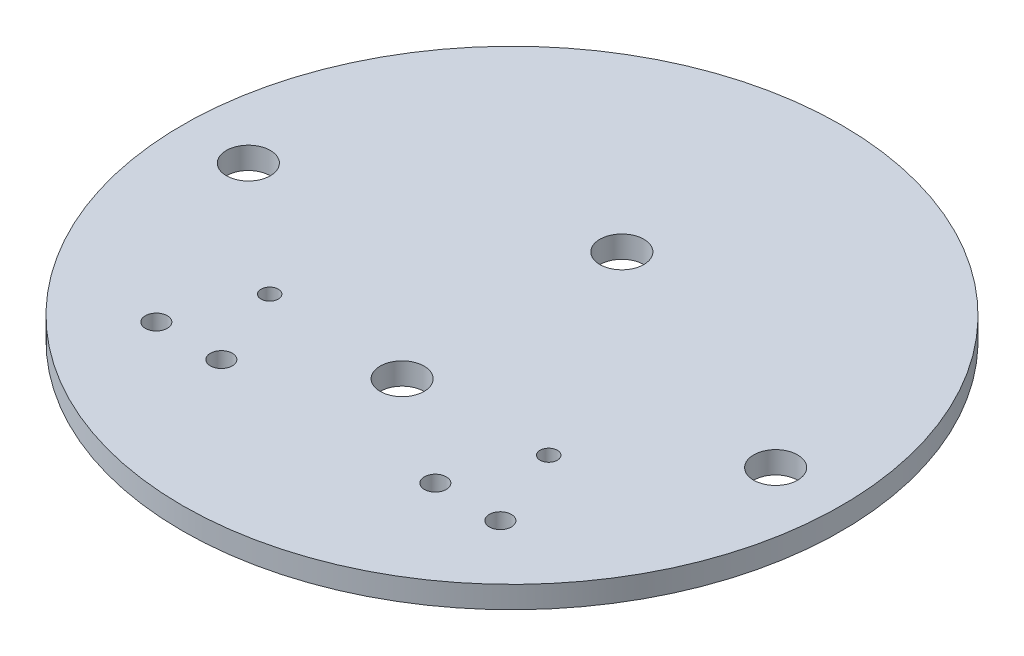
from build123d import *

# Parameters (mm, degrees)
SKETCH1_R           = 47.625
BOSS_EXTRUDE1_DEPTH = 3.175
SKETCH2_R           = 3.175
CUT_EXTRUDE1_DEPTH  = 263.398
SKETCH3_R           = 3.175
CUT_EXTRUDE2_DEPTH  = 25.4
SKETCH4_R           = 1.5875
SKETCH4_R_2         = 1.25
CUT_EXTRUDE3_DEPTH  = 50.8


with BuildPart() as part:
    # Sketch1 → Boss-Extrude1 (new body)
    with BuildSketch(Plane(origin=(0, 0, 0), x_dir=(1, 0, 0), z_dir=(0, 1, 0))):
        with Locations(Location((0, 0, 0), (0, 0, 270))):
            Circle(SKETCH1_R)
    extrude(amount=BOSS_EXTRUDE1_DEPTH)

    # Sketch2 → Cut-Extrude1 (cut)
    with BuildSketch(Plane(origin=(-55.039702575, 231.775, -116.088398355), x_dir=(-1, 0, 0), z_dir=(0, 1, 0))):
        with Locations(Location((-93.139702575, 116.088398355, 0), (0, 0, 90))):
            Circle(SKETCH2_R)
        with Locations(Location((-16.939702575, 116.088398355, 0), (0, 0, 90))):
            Circle(SKETCH2_R)
    extrude(amount=-CUT_EXTRUDE1_DEPTH, mode=Mode.SUBTRACT)

    # Sketch3 → Cut-Extrude2 (cut)
    with BuildSketch(Plane(origin=(-28.264398128, -3.175, -82.371298873), x_dir=(1, 0, 0), z_dir=(0, -1, 0))):
        with Locations(Location((28.264398128, 98.246298873, 0), (0, 0, 90))):
            Circle(SKETCH3_R)
        with Locations(Location((28.264398128, 66.496298873, 0), (0, 0, 90))):
            Circle(SKETCH3_R)
    extrude(amount=-CUT_EXTRUDE2_DEPTH, mode=Mode.SUBTRACT)

    # Sketch4 → Cut-Extrude3 (cut)
    with BuildSketch(Plane(origin=(-28.264398128, -3.175, -82.371298873), x_dir=(-1, 0, 0), z_dir=(0, -1, 0))):
        with Locations(Location((-3.404148128, -108.914298873, 0), (0, 0, 270))):
            Circle(SKETCH4_R)
        with Locations(Location((-12.802148128, -108.914298873, 0), (0, 0, 270))):
            Circle(SKETCH4_R)
        with Locations(Location((-43.726648128, -108.914298873, 0), (0, 0, 270))):
            Circle(SKETCH4_R)
        with Locations(Location((-53.124648128, -108.914298873, 0), (0, 0, 270))):
            Circle(SKETCH4_R)
        with Locations(Location((-8.103148128, -97.230298873, 0), (0, 0, 270))):
            Circle(SKETCH4_R_2)
        with Locations(Location((-48.425648128, -97.230298873, 0), (0, 0, 270))):
            Circle(SKETCH4_R_2)
    extrude(amount=-CUT_EXTRUDE3_DEPTH, mode=Mode.SUBTRACT)


solid = part.part
